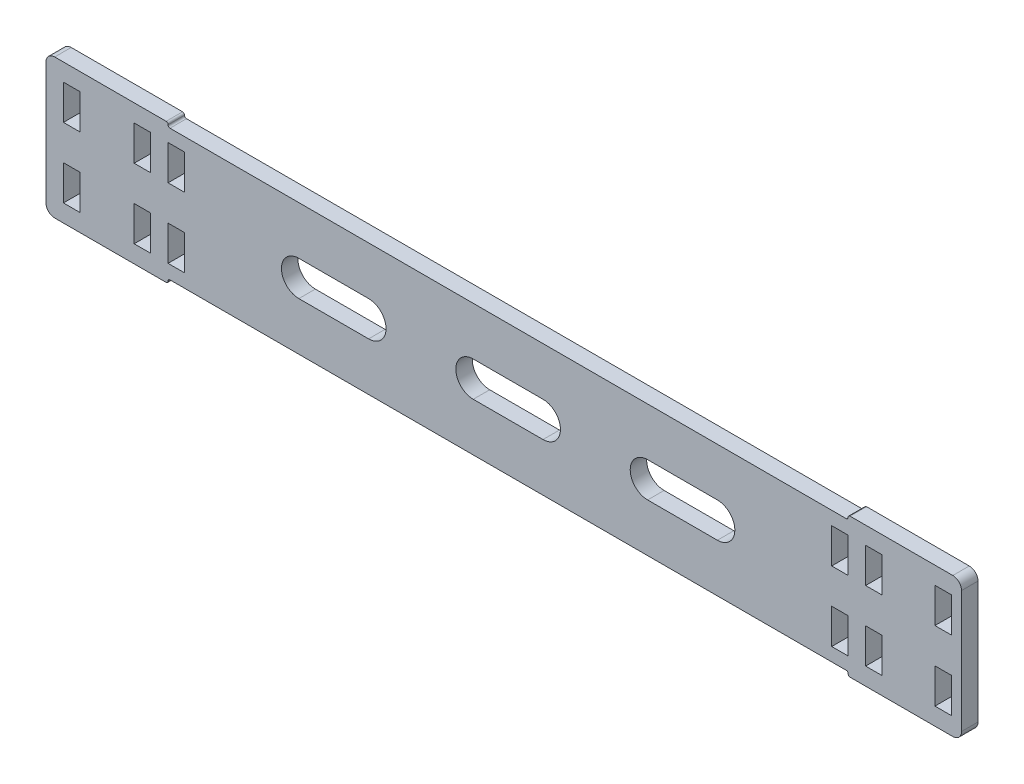
from build123d import *

# Parameters (mm, degrees)
SKETCH1_W           = 304.8
SKETCH1_H           = 50.8
SKETCH1_W_2         = 5.9944
SKETCH1_H_2         = 12.7
BOSS_EXTRUDE1_DEPTH = 5.9944
SKETCH3_W           = 247.65
SKETCH3_H           = 1.4875
CUT_EXTRUDE3_DEPTH  = 6.9944
FILLET4_R           = 0.7
SKETCH4_W           = 28.575
SKETCH4_H           = 50.8
BOSS_EXTRUDE2_DEPTH = 5.9944
SKETCH5_W           = 5.9944
SKETCH5_H           = 12.7
CUT_EXTRUDE4_DEPTH  = 6.9944
FILLET5_R           = 3.175
CUT_EXTRUDE5_DEPTH  = 6.9944
SKETCH7_W           = 5.9944
SKETCH7_H           = 12.7
CUT_EXTRUDE6_DEPTH  = 6.9944


with BuildPart() as part:
    # Sketch1 → Boss-Extrude1 (new body)
    with BuildSketch(Plane.XY):
        with Locations((-152.4, 25.4)):
            Rectangle(SKETCH1_W, SKETCH1_H)
        with Locations((-15.6972, 12.7)):
            Rectangle(SKETCH1_W_2, SKETCH1_H_2, mode=Mode.SUBTRACT)
        with Locations((-15.6972, 38.1)):
            Rectangle(SKETCH1_W_2, SKETCH1_H_2, mode=Mode.SUBTRACT)
        with Locations((-257.3528, 38.1)):
            Rectangle(SKETCH1_W_2, SKETCH1_H_2, mode=Mode.SUBTRACT)
        with Locations((-257.3528, 12.7)):
            Rectangle(SKETCH1_W_2, SKETCH1_H_2, mode=Mode.SUBTRACT)
        with Locations((-295.4528, 12.7)):
            Rectangle(SKETCH1_W_2, SKETCH1_H_2, mode=Mode.SUBTRACT)
        with Locations((-295.4528, 38.1)):
            Rectangle(SKETCH1_W_2, SKETCH1_H_2, mode=Mode.SUBTRACT)
    extrude(amount=BOSS_EXTRUDE1_DEPTH)

    # Sketch3 → Cut-Extrude3 (cut, through all)
    with BuildSketch(Plane.XY.offset(5.9944)):
        with Locations((-136.525, 50.05625)):
            Rectangle(SKETCH3_W, SKETCH3_H)
        with Locations((-136.525, 0.74375)):
            Rectangle(SKETCH3_W, SKETCH3_H)
    extrude(amount=-CUT_EXTRUDE3_DEPTH, mode=Mode.SUBTRACT)

    # Fillet4
    fillet4_edges = [part.edges().sort_by_distance(p)[0] for p in [
        (-260.35, 49.3125, 2.9972),
        (-260.35, 50.8, 2.9972),
        (-12.7, 50.8, 2.9972),
        (-12.7, 49.3125, 2.9972),
        (-12.7, 0, 2.9972),
        (-260.35, 0, 2.9972),
        (-260.35, 1.4875, 2.9972),
        (-12.7, 1.4875, 2.9972),
    ]]
    fillet(fillet4_edges, radius=FILLET4_R)

    # Sketch4 → Boss-Extrude2 (add)
    with BuildSketch(Plane.XY.offset(5.9944)):
        with Locations((14.2875, 25.4)):
            Rectangle(SKETCH4_W, SKETCH4_H)
    extrude(amount=-BOSS_EXTRUDE2_DEPTH)

    # Sketch5 → Cut-Extrude4 (cut, through all)
    with BuildSketch(Plane.XY.offset(5.9944)):
        with Locations((21.893276, 38.1)):
            Rectangle(SKETCH5_W, SKETCH5_H)
        with Locations((21.893276, 12.7)):
            Rectangle(SKETCH5_W, SKETCH5_H)
    extrude(amount=-CUT_EXTRUDE4_DEPTH, mode=Mode.SUBTRACT)

    # Fillet5
    fillet5_edges = [part.edges().sort_by_distance(p)[0] for p in [
        (28.575, 50.8, 2.9972),
        (28.575, 0, 2.9972),
        (-304.8, 0, 2.9972),
        (-304.8, 50.8, 2.9972),
    ]]
    fillet(fillet5_edges, radius=FILLET5_R)

    # Sketch6 → Cut-Extrude5 (cut, through all)
    with BuildSketch(Plane.XY.offset(5.9944)):
        with BuildLine():
            Line((-123.825, 19.05), (-149.225, 19.05))
            ThreePointArc((-149.225, 19.05), (-155.575, 25.4), (-149.225, 31.75))
            Line((-149.225, 31.75), (-123.825, 31.75))
            ThreePointArc((-123.825, 31.75), (-117.475, 25.4), (-123.825, 19.05))
        make_face()
        with BuildLine():
            Line((-60.325, 19.05), (-85.725, 19.05))
            ThreePointArc((-85.725, 19.05), (-92.075, 25.4), (-85.725, 31.75))
            Line((-85.725, 31.75), (-60.325, 31.75))
            ThreePointArc((-60.325, 31.75), (-53.975, 25.4), (-60.325, 19.05))
        make_face()
        with BuildLine():
            Line((-187.325, 19.05), (-212.725, 19.05))
            ThreePointArc((-212.725, 19.05), (-219.075, 25.4), (-212.725, 31.75))
            Line((-212.725, 31.75), (-187.325, 31.75))
            ThreePointArc((-187.325, 31.75), (-180.975, 25.4), (-187.325, 19.05))
        make_face()
    extrude(amount=-CUT_EXTRUDE5_DEPTH, mode=Mode.SUBTRACT)

    # Sketch7 → Cut-Extrude6 (cut, through all)
    with BuildSketch(Plane.XY.offset(5.9944)):
        with Locations((-269.6972, 38.1)):
            Rectangle(SKETCH7_W, SKETCH7_H)
        with Locations((-3.3528, 38.1)):
            Rectangle(SKETCH7_W, SKETCH7_H)
        with Locations((-269.6972, 12.7)):
            Rectangle(SKETCH7_W, SKETCH7_H)
        with Locations((-3.3528, 12.7)):
            Rectangle(SKETCH7_W, SKETCH7_H)
    extrude(amount=-CUT_EXTRUDE6_DEPTH, mode=Mode.SUBTRACT)


solid = part.part
